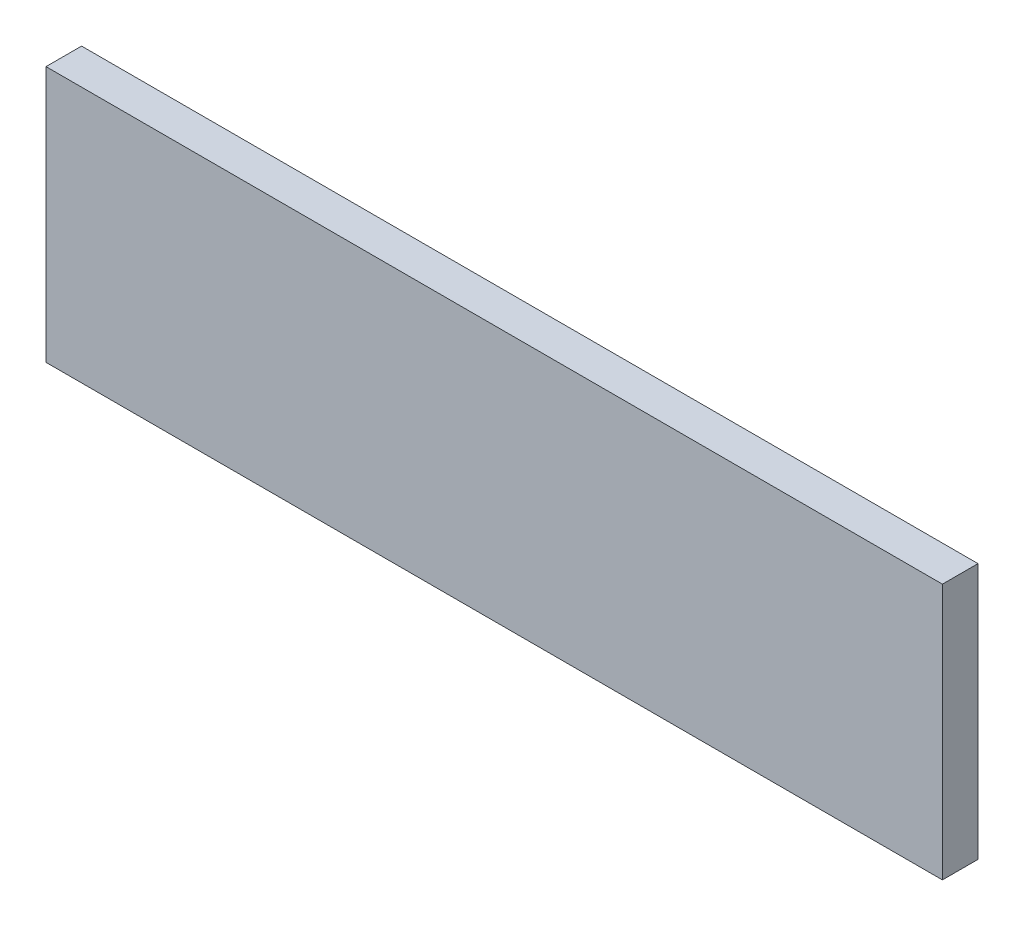
from build123d import *

# Parameters (mm, degrees)
SKETCH1_W           = 40
SKETCH1_H           = 11.43
BOSS_EXTRUDE1_DEPTH = 1.5875


with BuildPart() as part:
    # Sketch1 → Boss-Extrude1 (new body)
    with BuildSketch(Plane.XY):
        with Locations((-44.862738222, 6.327918823)):
            Rectangle(SKETCH1_W, SKETCH1_H)
    extrude(amount=BOSS_EXTRUDE1_DEPTH)


solid = part.part
